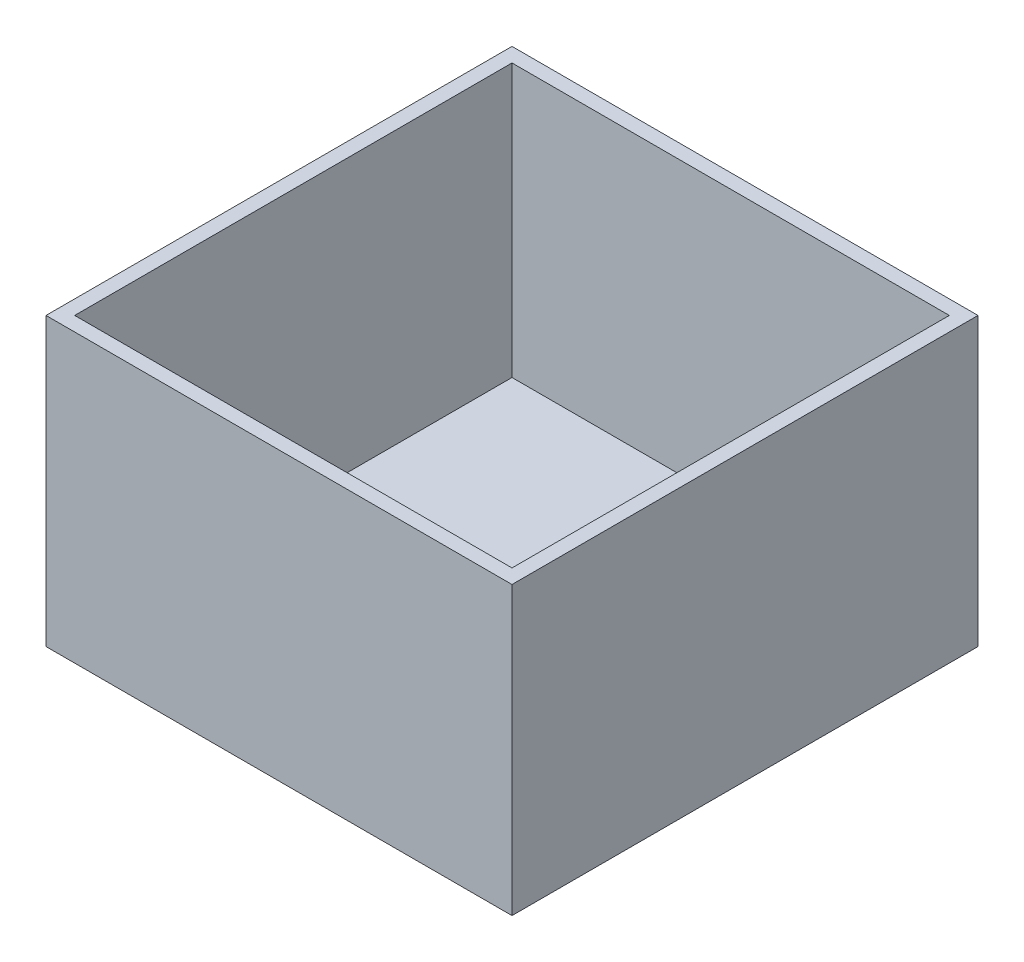
from build123d import *

# Parameters (mm, degrees)
SKETCH1_W           = 82.55
SKETCH1_H           = 82.55
BOSS_EXTRUDE1_DEPTH = 50.8
SHELL1_T            = -2.54


with BuildPart() as part:
    # Sketch1 → Boss-Extrude1 (new body)
    with BuildSketch(Plane(origin=(0, 0, 0), x_dir=(1, 0, 0), z_dir=(0, 1, 0))):
        with Locations((41.275, -41.275)):
            Rectangle(SKETCH1_W, SKETCH1_H)
    extrude(amount=BOSS_EXTRUDE1_DEPTH)

    # Shell1
    shell1_openings = [part.faces().sort_by_distance(p)[0] for p in [
        (41.275, 50.8, 41.275),
    ]]
    offset(amount=SHELL1_T, openings=shell1_openings, kind=Kind.INTERSECTION)


solid = part.part
